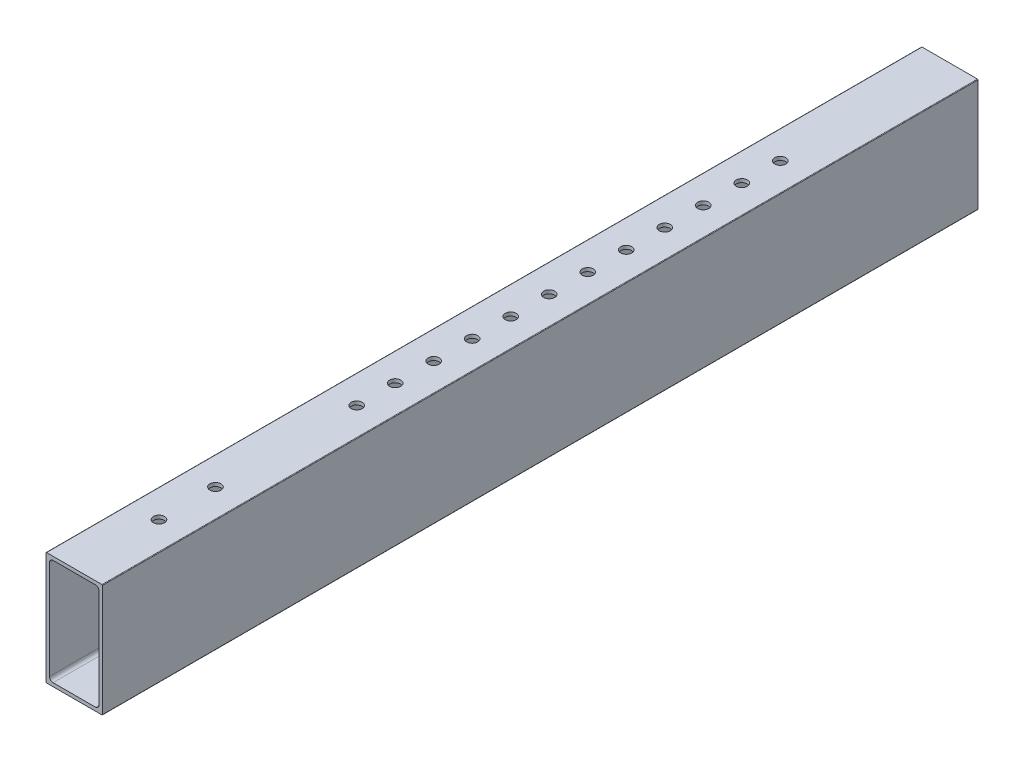
from build123d import *

# Parameters (mm, degrees)
BOSS_EXTRUDE1_START     = -88.9
BOSS_EXTRUDE1_DEPTH     = 393.7
SKETCH3_R               = 2.4892
CUT_EXTRUDE2_DEPTH      = 1
CUT_EXTRUDE2_DEPTH_BACK = 51.8


with BuildPart() as part:
    # Sketch1 → Boss-Extrude1 (new body)
    with BuildSketch(Plane(origin=(0, 0, 0), x_dir=(-1, 0, 0), z_dir=(0, 0, -1)).offset(BOSS_EXTRUDE1_START)):
        with BuildLine():
            Line((-12.7, 25.146), (-12.7, -25.146))
            ThreePointArc((-12.7, -25.146), (-12.625605122, -25.325605122), (-12.446, -25.4))
            Line((-12.446, -25.4), (12.446, -25.4))
            ThreePointArc((12.446, -25.4), (12.625605122, -25.325605122), (12.7, -25.146))
            Line((12.7, -25.146), (12.7, 25.146))
            ThreePointArc((12.7, 25.146), (12.625605122, 25.325605122), (12.446, 25.4))
            Line((12.446, 25.4), (-12.446, 25.4))
            ThreePointArc((-12.446, 25.4), (-12.625605122, 25.325605122), (-12.7, 25.146))
        make_face()
        with BuildLine():
            Line((-11.1125, -22.225), (-11.1125, 22.225))
            ThreePointArc((-11.1125, 22.225), (-10.647532015, 23.347532015), (-9.525, 23.8125))
            Line((-9.525, 23.8125), (9.525, 23.8125))
            ThreePointArc((9.525, 23.8125), (10.647532015, 23.347532015), (11.1125, 22.225))
            Line((11.1125, 22.225), (11.1125, -22.225))
            ThreePointArc((11.1125, -22.225), (10.647532015, -23.347532015), (9.525, -23.8125))
            Line((9.525, -23.8125), (-9.525, -23.8125))
            ThreePointArc((-9.525, -23.8125), (-10.647532015, -23.347532015), (-11.1125, -22.225))
        make_face(mode=Mode.SUBTRACT)
    extrude(amount=-BOSS_EXTRUDE1_DEPTH)

    # Sketch3 → Cut-Extrude2 (cut, two sides)
    with BuildSketch(Plane.XZ.offset(25.4)) as cut_extrude2_sk:
        with Locations((0, 165.1)):
            Circle(SKETCH3_R)
        with Locations((0, 182.418181818)):
            Circle(SKETCH3_R)
        with Locations((0, 199.736363636)):
            Circle(SKETCH3_R)
        with Locations((0, 217.054545455)):
            Circle(SKETCH3_R)
        with Locations((0, 234.372727273)):
            Circle(SKETCH3_R)
        with Locations((0, 251.690909091)):
            Circle(SKETCH3_R)
        with Locations((0, 269.009090909)):
            Circle(SKETCH3_R)
        with Locations((0, 286.327272727)):
            Circle(SKETCH3_R)
        with Locations((0, 303.645454545)):
            Circle(SKETCH3_R)
        with Locations((0, 320.963636364)):
            Circle(SKETCH3_R)
        with Locations((0, 338.281818182)):
            Circle(SKETCH3_R)
        with Locations((0, 419.1)):
            Circle(SKETCH3_R)
        with Locations((0, 444.5)):
            Circle(SKETCH3_R)
        with Locations((0, 355.6)):
            Circle(SKETCH3_R)
    extrude(amount=CUT_EXTRUDE2_DEPTH, mode=Mode.SUBTRACT)
    extrude(cut_extrude2_sk.sketch, amount=-CUT_EXTRUDE2_DEPTH_BACK, mode=Mode.SUBTRACT)


solid = part.part
